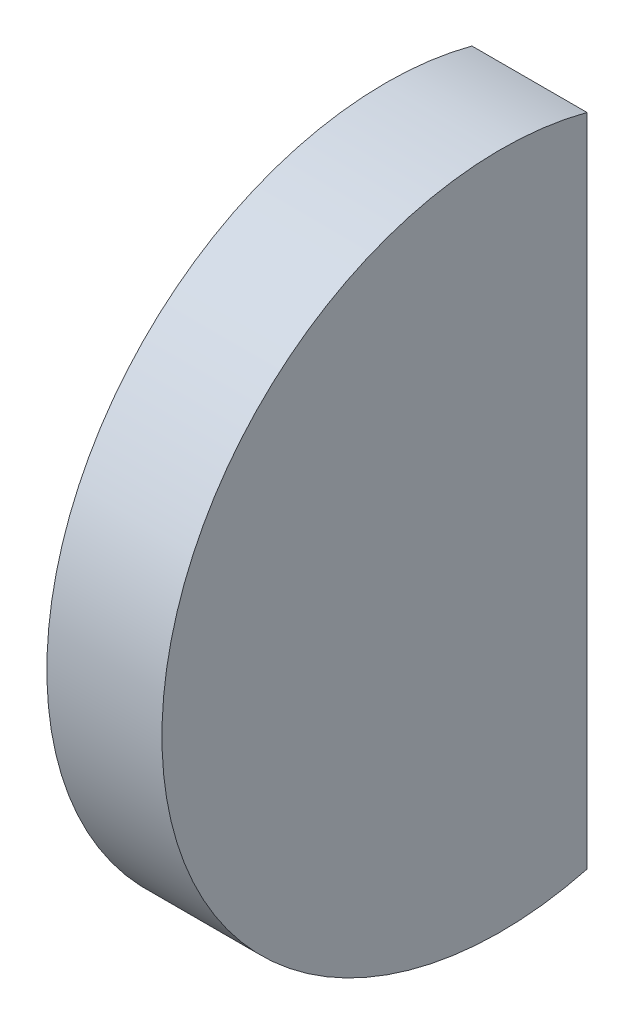
from build123d import *

# Parameters (mm, degrees)
CUT_EXTRUDE_1_DEPTH = 6


with BuildPart() as part:
    # Эскиз1 → Повернуть1 (revolve)
    with BuildSketch(Plane.XY):
        with BuildLine():
            Line((1.263890931, 11), (5, 11))
            Line((5, 11), (5, 0))
            Line((5, 0), (0, 0))
            ThreePointArc((0, 0), (0.317008759, 5.536185968), (1.263890931, 11))
        make_face()
    revolve(axis=Axis((0, 0, 0), (1, 0, 0)))

    # Эскиз2 → Вырез-Вытянуть1 (cut, through all)
    with BuildSketch(Plane(origin=(5, 0, 0), x_dir=(0, 0, -1), z_dir=(1, 0, 0))):
        Polygon((2.8, 71.965194328), (2.8, 10.637668918), (2.8, -10.637668918), (2.8, -71.965194328), (125.455050821, -71.965194328), (125.455050821, 71.965194328), align=None)
    extrude(amount=-CUT_EXTRUDE_1_DEPTH, mode=Mode.SUBTRACT)


solid = part.part
